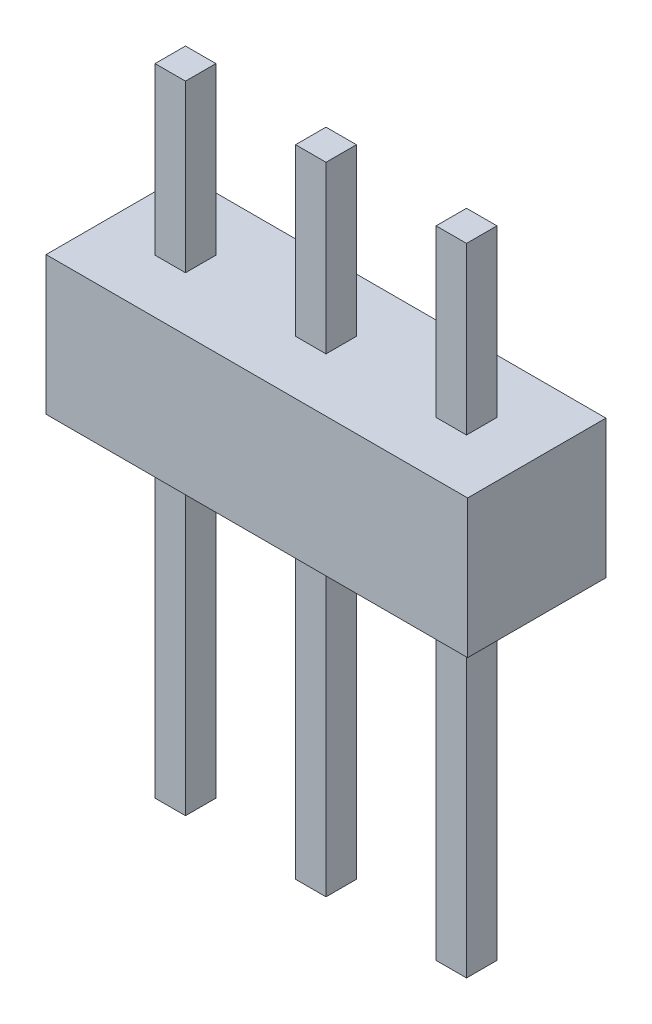
from build123d import *

# Parameters (mm, degrees)
SKETCH1_W             = 7.62
SKETCH1_H             = 2.5
BOSS_EXTRUDE1_DEPTH   = 1.25
SKETCH2_W             = 0.55
SKETCH2_H             = 0.55
BOSS_EXTRUDE2_DEPTH   = 6
BOSS_EXTRUDE2_2_DEPTH = 6
BOSS_EXTRUDE2_3_DEPTH = 6
SKETCH2_2_W           = 0.55
SKETCH2_2_H           = 0.55
BOSS_EXTRUDE3_DEPTH   = 5.5
BOSS_EXTRUDE3_2_DEPTH = 5.5
BOSS_EXTRUDE3_3_DEPTH = 5.5


with BuildPart() as part:
    # Sketch1 → Boss-Extrude1 (new body, symmetric)
    with BuildSketch(Plane.XY):
        with Locations((3.81, 1.25)):
            Rectangle(SKETCH1_W, SKETCH1_H)
    extrude(amount=BOSS_EXTRUDE1_DEPTH, both=True)


with BuildPart() as body_2:
    # Sketch2 → Boss-Extrude2 (new body)
    with BuildSketch(Plane.XZ):
        with Locations((3.81, 0)):
            Rectangle(SKETCH2_W, SKETCH2_H)
    extrude(amount=BOSS_EXTRUDE2_DEPTH)


with BuildPart() as body_3:
    # Sketch2 → Boss-Extrude2 2 (new body)
    with BuildSketch(Plane.XZ):
        with Locations((1.27, 0)):
            Rectangle(SKETCH2_W, SKETCH2_H)
    extrude(amount=BOSS_EXTRUDE2_2_DEPTH)


with BuildPart() as body_4:
    # Sketch2 → Boss-Extrude2 3 (new body)
    with BuildSketch(Plane.XZ):
        with Locations((6.35, 0)):
            Rectangle(SKETCH2_W, SKETCH2_H)
    extrude(amount=BOSS_EXTRUDE2_3_DEPTH)


with BuildPart() as body_5:
    # Sketch2_2 → Boss-Extrude3 (new body)
    with BuildSketch(Plane.XZ):
        with Locations((3.81, 0)):
            Rectangle(SKETCH2_2_W, SKETCH2_2_H)
    extrude(amount=-BOSS_EXTRUDE3_DEPTH)


with BuildPart() as body_6:
    # Sketch2_2 → Boss-Extrude3 2 (new body)
    with BuildSketch(Plane.XZ):
        with Locations((1.27, 0)):
            Rectangle(SKETCH2_2_W, SKETCH2_2_H)
    extrude(amount=-BOSS_EXTRUDE3_2_DEPTH)


with BuildPart() as body_7:
    # Sketch2_2 → Boss-Extrude3 3 (new body)
    with BuildSketch(Plane.XZ):
        with Locations((6.35, 0)):
            Rectangle(SKETCH2_2_W, SKETCH2_2_H)
    extrude(amount=-BOSS_EXTRUDE3_3_DEPTH)


solid = Compound([part.part, body_2.part, body_3.part, body_4.part, body_5.part, body_6.part, body_7.part])
